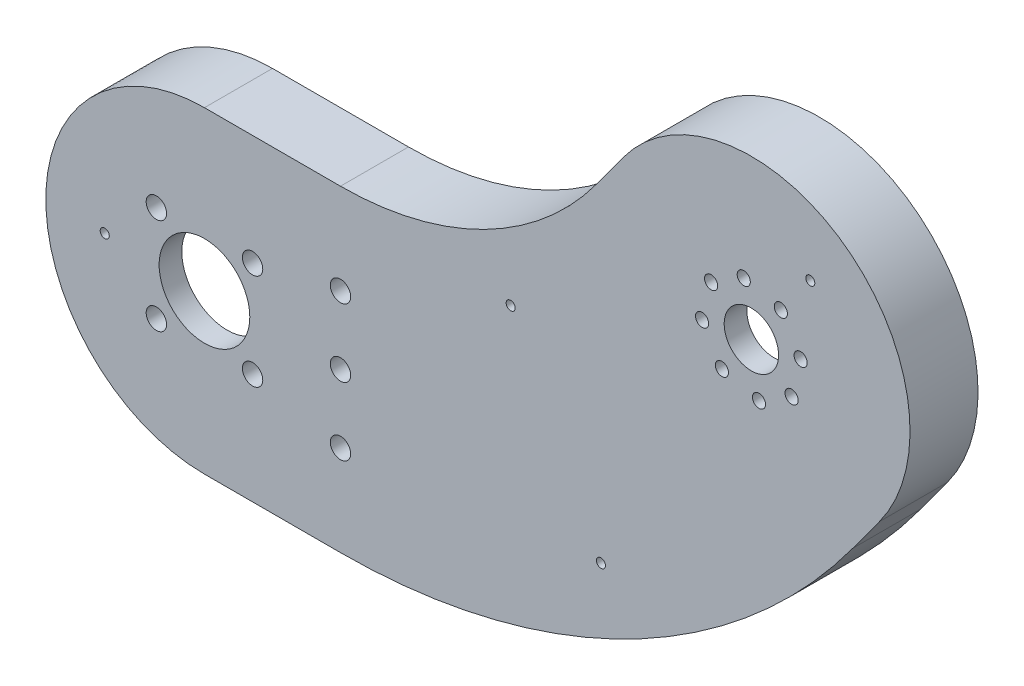
from build123d import *

# Parameters (mm, degrees)
EXTRUDE_1_DEPTH                 = 20
CHAMFER_1_SIZE                  = 10
CUT_EXTRUDE_1_DEPTH             = 15
CUT_EXTRUDE_3_REACH             = 22
SKETCH_4_R                      = 10
SKETCH_4_R_2                    = 2.25
SKETCH_5_R                      = 4
EXTRUDE_2_DEPTH                 = 5
FILLET_1_R                      = 5
CUT_EXTRUDE_4_REACH             = 12
SKETCH_6_R                      = 1
FILLET_2_R                      = 5
CUT_EXTRUDE_5_REACH             = 22
SKETCH_3_R                      = 1.45
SKETCH_3_R_2                    = 6
CUT_EXTRUDE_5_DIRECTION_2_DEPTH = 1.0000001
EXTRUDE_3_DEPTH                 = 13
CUT_EXTRUDE_6_DEPTH             = 5


with BuildPart() as part:
    # 스케치1 → 보스-돌출1 (new body)
    with BuildSketch(Plane.XY):
        with BuildLine():
            Line((0, 35), (30, 35))
            ThreePointArc((30, 35), (61.66442834, 42.571128651), (86.479272091, 63.646743489))
            Line((86.479272091, 63.646743489), (92.386880164, 71.71521093))
            ThreePointArc((92.386880164, 71.71521093), (141.303144465, 79.27821872), (148.866152254, 30.361954419))
            Line((148.866152254, 30.361954419), (142.958544181, 22.293486977))
            ThreePointArc((142.958544181, 22.293486977), (93.32885668, -19.857742698), (30, -35))
            Line((30, -35), (0, -35))
            ThreePointArc((0, -35), (-35, 0), (0, 35))
        make_face()
    extrude(amount=EXTRUDE_1_DEPTH)

    # 모따기1
    chamfer_1_edges = [part.edges().sort_by_distance(p)[0] for p in [
        (15, -35, 0),
        (-35, 0, 0),
        (15, 35, 0),
        (61.66442834, 42.571128651, 0),
        (89.433076127, 67.680977209, 0),
        (141.303144465, 79.27821872, 0),
        (145.912348218, 26.327720698, 0),
        (93.32885668, -19.857742698, 0),
    ]]
    chamfer(chamfer_1_edges, length=CHAMFER_1_SIZE)

    # 스케치2 → 컷-돌출1 (cut)
    with BuildSketch(Plane(origin=(0, 0, 0), x_dir=(-1, 0, 0), z_dir=(0, 0, -1))):
        with BuildLine():
            Line((-30, -25), (0, -25))
            ThreePointArc((0, -25), (25, 0), (0, 25))
            Line((0, 25), (-30, 25))
            ThreePointArc((-30, 25), (-66.187918103, 33.652718458), (-94.547739532, 57.739135415))
            Line((-94.547739532, 57.739135415), (-100.455347605, 65.807602857))
            ThreePointArc((-100.455347605, 65.807602857), (-135.395536392, 71.209751278), (-140.797684813, 36.269562492))
            Line((-140.797684813, 36.269562492), (-134.89007674, 28.20109505))
            ThreePointArc((-134.89007674, 28.20109505), (-88.805366917, -10.939332505), (-30, -25))
        make_face()
    extrude(amount=-CUT_EXTRUDE_1_DEPTH, mode=Mode.SUBTRACT)

    # 스케치4 → 컷-돌출3 (cut, up to next)
    with BuildSketch(Plane.XY.offset(20), mode=Mode.PRIVATE) as cut_extrude_3_sk1:
        Circle(SKETCH_4_R)
    cut_extrude_3_tool1 = extrude(cut_extrude_3_sk1.sketch, amount=-CUT_EXTRUDE_3_REACH, mode=Mode.PRIVATE) & part.part
    add(cut_extrude_3_tool1.solids().sort_by_distance((0, 0, 20))[0], mode=Mode.SUBTRACT)
    # 스케치4 → 컷-돌출3 (cut, up to next)
    with BuildSketch(Plane.XY.offset(20), mode=Mode.PRIVATE) as cut_extrude_3_sk2:
        with Locations((10.606601718, 10.606601718)):
            Circle(SKETCH_4_R_2)
    cut_extrude_3_tool2 = extrude(cut_extrude_3_sk2.sketch, amount=-CUT_EXTRUDE_3_REACH, mode=Mode.PRIVATE) & part.part
    add(cut_extrude_3_tool2.solids().sort_by_distance((10.606602, 10.606602, 20))[0], mode=Mode.SUBTRACT)
    # 스케치4 → 컷-돌출3 (cut, up to next)
    with BuildSketch(Plane.XY.offset(20), mode=Mode.PRIVATE) as cut_extrude_3_sk3:
        with Locations((-10.606601718, -10.606601718)):
            Circle(SKETCH_4_R_2)
    cut_extrude_3_tool3 = extrude(cut_extrude_3_sk3.sketch, amount=-CUT_EXTRUDE_3_REACH, mode=Mode.PRIVATE) & part.part
    add(cut_extrude_3_tool3.solids().sort_by_distance((-10.606602, -10.606602, 20))[0], mode=Mode.SUBTRACT)
    # 스케치4 → 컷-돌출3 (cut, up to next)
    with BuildSketch(Plane.XY.offset(20), mode=Mode.PRIVATE) as cut_extrude_3_sk4:
        with Locations((10.606601718, -10.606601718)):
            Circle(SKETCH_4_R_2)
    cut_extrude_3_tool4 = extrude(cut_extrude_3_sk4.sketch, amount=-CUT_EXTRUDE_3_REACH, mode=Mode.PRIVATE) & part.part
    add(cut_extrude_3_tool4.solids().sort_by_distance((10.606602, -10.606602, 20))[0], mode=Mode.SUBTRACT)
    # 스케치4 → 컷-돌출3 (cut, up to next)
    with BuildSketch(Plane.XY.offset(20), mode=Mode.PRIVATE) as cut_extrude_3_sk5:
        with Locations((-10.606601718, 10.606601718)):
            Circle(SKETCH_4_R_2)
    cut_extrude_3_tool5 = extrude(cut_extrude_3_sk5.sketch, amount=-CUT_EXTRUDE_3_REACH, mode=Mode.PRIVATE) & part.part
    add(cut_extrude_3_tool5.solids().sort_by_distance((-10.606602, 10.606602, 20))[0], mode=Mode.SUBTRACT)
    # 스케치4 → 컷-돌출3 (cut, up to next)
    with BuildSketch(Plane.XY.offset(20), mode=Mode.PRIVATE) as cut_extrude_3_sk6:
        with Locations((30, 0)):
            Circle(SKETCH_4_R_2)
    cut_extrude_3_tool6 = extrude(cut_extrude_3_sk6.sketch, amount=-CUT_EXTRUDE_3_REACH, mode=Mode.PRIVATE) & part.part
    add(cut_extrude_3_tool6.solids().sort_by_distance((30, 0, 20))[0], mode=Mode.SUBTRACT)
    # 스케치4 → 컷-돌출3 (cut, up to next)
    with BuildSketch(Plane.XY.offset(20), mode=Mode.PRIVATE) as cut_extrude_3_sk7:
        with Locations((30, 15)):
            Circle(SKETCH_4_R_2)
    cut_extrude_3_tool7 = extrude(cut_extrude_3_sk7.sketch, amount=-CUT_EXTRUDE_3_REACH, mode=Mode.PRIVATE) & part.part
    add(cut_extrude_3_tool7.solids().sort_by_distance((30, 15, 20))[0], mode=Mode.SUBTRACT)
    # 스케치4 → 컷-돌출3 (cut, up to next)
    with BuildSketch(Plane.XY.offset(20), mode=Mode.PRIVATE) as cut_extrude_3_sk8:
        with Locations((30, -15)):
            Circle(SKETCH_4_R_2)
    cut_extrude_3_tool8 = extrude(cut_extrude_3_sk8.sketch, amount=-CUT_EXTRUDE_3_REACH, mode=Mode.PRIVATE) & part.part
    add(cut_extrude_3_tool8.solids().sort_by_distance((30, -15, 20))[0], mode=Mode.SUBTRACT)

    # 스케치5 → 보스-돌출2 (add)
    with BuildSketch(Plane(origin=(0, 0, 15), x_dir=(-1, 0, 0), z_dir=(0, 0, -1))):
        with Locations((-87.448319988, -8.263809447)):
            Circle(SKETCH_5_R)
        with Locations((22, 0)):
            Circle(SKETCH_5_R)
        with Locations((-67.544965032, 30.977195401)):
            Circle(SKETCH_5_R)
        with Locations((-133.62325397, 68.789211046)):
            Circle(SKETCH_5_R)
    extrude(amount=EXTRUDE_2_DEPTH)

    # 필렛1
    fillet_1_edges = [part.edges().sort_by_distance(p)[0] for p in [
        (86.405731085, -12.125545893, 12.5),
        (91.180070129, -9.703962525, 12.5),
        (-24.840909091, 2.81588983, 12.5),
        (-24.840909091, -2.81588983, 12.5),
        (63.852594529, 32.515506185, 12.5),
        (68.485091763, 34.86514624, 12.5),
        (137.573543259, 69.417871947, 12.5),
        (133.029560176, 72.744906646, 12.5),
    ]]
    fillet(fillet_1_edges, radius=FILLET_1_R)

    # 스케치6 → 컷-돌출4 (cut, up to next)
    with BuildSketch(Plane(origin=(0, 0, 10), x_dir=(-1, 0, 0), z_dir=(0, 0, -1)), mode=Mode.PRIVATE) as cut_extrude_4_sk1:
        with Locations((-87.448319988, -8.263809447)):
            Circle(SKETCH_6_R)
    cut_extrude_4_tool1 = extrude(cut_extrude_4_sk1.sketch, amount=-CUT_EXTRUDE_4_REACH, mode=Mode.PRIVATE) & part.part
    add(cut_extrude_4_tool1.solids().sort_by_distance((87.44832, -8.263809, 10))[0], mode=Mode.SUBTRACT)
    # 스케치6 → 컷-돌출4 (cut, up to next)
    with BuildSketch(Plane(origin=(0, 0, 10), x_dir=(-1, 0, 0), z_dir=(0, 0, -1)), mode=Mode.PRIVATE) as cut_extrude_4_sk2:
        with Locations((22, 0)):
            Circle(SKETCH_6_R)
    cut_extrude_4_tool2 = extrude(cut_extrude_4_sk2.sketch, amount=-CUT_EXTRUDE_4_REACH, mode=Mode.PRIVATE) & part.part
    add(cut_extrude_4_tool2.solids().sort_by_distance((-22, 0, 10))[0], mode=Mode.SUBTRACT)
    # 스케치6 → 컷-돌출4 (cut, up to next)
    with BuildSketch(Plane(origin=(0, 0, 10), x_dir=(-1, 0, 0), z_dir=(0, 0, -1)), mode=Mode.PRIVATE) as cut_extrude_4_sk3:
        with Locations((-67.544965032, 30.977195401)):
            Circle(SKETCH_6_R)
    cut_extrude_4_tool3 = extrude(cut_extrude_4_sk3.sketch, amount=-CUT_EXTRUDE_4_REACH, mode=Mode.PRIVATE) & part.part
    add(cut_extrude_4_tool3.solids().sort_by_distance((67.544965, 30.977195, 10))[0], mode=Mode.SUBTRACT)
    # 스케치6 → 컷-돌출4 (cut, up to next)
    with BuildSketch(Plane(origin=(0, 0, 10), x_dir=(-1, 0, 0), z_dir=(0, 0, -1)), mode=Mode.PRIVATE) as cut_extrude_4_sk4:
        with Locations((-133.62325397, 68.789211046)):
            Circle(SKETCH_6_R)
    cut_extrude_4_tool4 = extrude(cut_extrude_4_sk4.sketch, amount=-CUT_EXTRUDE_4_REACH, mode=Mode.PRIVATE) & part.part
    add(cut_extrude_4_tool4.solids().sort_by_distance((133.623254, 68.789211, 10))[0], mode=Mode.SUBTRACT)

    # 필렛2
    fillet_2_edges = [part.edges().sort_by_distance(p)[0] for p in [
        (-35, 0, 10),
        (15, -35, 10),
        (15, 35, 10),
        (93.32885668, -19.857742698, 10),
        (61.66442834, 42.571128651, 10),
        (145.912348218, 26.327720698, 10),
        (89.433076127, 67.680977209, 10),
        (141.303144465, 79.27821872, 10),
    ]]
    fillet(fillet_2_edges, radius=FILLET_2_R)

    # 스케치3 → 컷-돌출5 (cut, up to next)
    with BuildSketch(Plane.XY.offset(20), mode=Mode.PRIVATE) as cut_extrude_5_sk1:
        with Locations((127.12488509, 59.91389686)):
            Circle(SKETCH_3_R)
    cut_extrude_5_tool1 = extrude(cut_extrude_5_sk1.sketch, amount=-CUT_EXTRUDE_5_REACH, mode=Mode.PRIVATE) & part.part
    add(cut_extrude_5_tool1.solids().sort_by_distance((127.124885, 59.913897, 20))[0], mode=Mode.SUBTRACT)
    # 스케치3 → 컷-돌출5 (cut, up to next)
    with BuildSketch(Plane.XY.offset(20), mode=Mode.PRIVATE) as cut_extrude_5_sk2:
        with Locations((129.501830395, 44.540213794)):
            Circle(SKETCH_3_R)
    cut_extrude_5_tool2 = extrude(cut_extrude_5_sk2.sketch, amount=-CUT_EXTRUDE_5_REACH, mode=Mode.PRIVATE) & part.part
    add(cut_extrude_5_tool2.solids().sort_by_distance((129.50183, 44.540214, 20))[0], mode=Mode.SUBTRACT)
    # 스케치3 → 컷-돌출5 (cut, up to next)
    with BuildSketch(Plane.XY.offset(20), mode=Mode.PRIVATE) as cut_extrude_5_sk3:
        with Locations((114.128147329, 42.163268489)):
            Circle(SKETCH_3_R)
    cut_extrude_5_tool3 = extrude(cut_extrude_5_sk3.sketch, amount=-CUT_EXTRUDE_5_REACH, mode=Mode.PRIVATE) & part.part
    add(cut_extrude_5_tool3.solids().sort_by_distance((114.128147, 42.163268, 20))[0], mode=Mode.SUBTRACT)
    # 스케치3 → 컷-돌출5 (cut, up to next)
    with BuildSketch(Plane.XY.offset(20), mode=Mode.PRIVATE) as cut_extrude_5_sk4:
        with Locations((111.751202023, 57.536951555)):
            Circle(SKETCH_3_R)
    cut_extrude_5_tool4 = extrude(cut_extrude_5_sk4.sketch, amount=-CUT_EXTRUDE_5_REACH, mode=Mode.PRIVATE) & part.part
    add(cut_extrude_5_tool4.solids().sort_by_distance((111.751202, 57.536952, 20))[0], mode=Mode.SUBTRACT)
    # 스케치3 → 컷-돌출5 (cut, up to next)
    with BuildSketch(Plane.XY.offset(20), mode=Mode.PRIVATE) as cut_extrude_5_sk5:
        with Locations((120.626516209, 51.038582674)):
            Circle(SKETCH_3_R_2)
    cut_extrude_5_tool5 = extrude(cut_extrude_5_sk5.sketch, amount=-CUT_EXTRUDE_5_REACH, mode=Mode.PRIVATE) & part.part
    add(cut_extrude_5_tool5.solids().sort_by_distance((120.626516, 51.038583, 20))[0], mode=Mode.SUBTRACT)
    # 스케치3 → 컷-돌출5 (cut, up to next)
    with BuildSketch(Plane.XY.offset(20), mode=Mode.PRIVATE) as cut_extrude_5_sk6:
        with Locations((118.945762065, 61.909418222)):
            Circle(SKETCH_3_R)
    cut_extrude_5_tool6 = extrude(cut_extrude_5_sk6.sketch, amount=-CUT_EXTRUDE_5_REACH, mode=Mode.PRIVATE) & part.part
    add(cut_extrude_5_tool6.solids().sort_by_distance((118.945762, 61.909418, 20))[0], mode=Mode.SUBTRACT)
    # 스케치3 → 컷-돌출5 (cut, up to next)
    with BuildSketch(Plane.XY.offset(20), mode=Mode.PRIVATE) as cut_extrude_5_sk7:
        with Locations((131.497351757, 52.719336818)):
            Circle(SKETCH_3_R)
    cut_extrude_5_tool7 = extrude(cut_extrude_5_sk7.sketch, amount=-CUT_EXTRUDE_5_REACH, mode=Mode.PRIVATE) & part.part
    add(cut_extrude_5_tool7.solids().sort_by_distance((131.497352, 52.719337, 20))[0], mode=Mode.SUBTRACT)
    # 스케치3 → 컷-돌출5 (cut, up to next)
    with BuildSketch(Plane.XY.offset(20), mode=Mode.PRIVATE) as cut_extrude_5_sk8:
        with Locations((122.307270353, 40.167747126)):
            Circle(SKETCH_3_R)
    cut_extrude_5_tool8 = extrude(cut_extrude_5_sk8.sketch, amount=-CUT_EXTRUDE_5_REACH, mode=Mode.PRIVATE) & part.part
    add(cut_extrude_5_tool8.solids().sort_by_distance((122.30727, 40.167747, 20))[0], mode=Mode.SUBTRACT)
    # 스케치3 → 컷-돌출5 (cut, up to next)
    with BuildSketch(Plane.XY.offset(20), mode=Mode.PRIVATE) as cut_extrude_5_sk9:
        with Locations((109.755680661, 49.35782853)):
            Circle(SKETCH_3_R)
    cut_extrude_5_tool9 = extrude(cut_extrude_5_sk9.sketch, amount=-CUT_EXTRUDE_5_REACH, mode=Mode.PRIVATE) & part.part
    add(cut_extrude_5_tool9.solids().sort_by_distance((109.755681, 49.357829, 20))[0], mode=Mode.SUBTRACT)

    # 스케치3 → 컷-돌출5 direction 2 (cut)
    with BuildSketch(Plane.XY.offset(20)):
        with Locations((127.12488509, 59.91389686)):
            Circle(SKETCH_3_R)
        with Locations((129.501830395, 44.540213794)):
            Circle(SKETCH_3_R)
        with Locations((114.128147329, 42.163268489)):
            Circle(SKETCH_3_R)
        with Locations((111.751202023, 57.536951555)):
            Circle(SKETCH_3_R)
        with Locations((120.626516209, 51.038582674)):
            Circle(SKETCH_3_R_2)
        with Locations((118.945762065, 61.909418222)):
            Circle(SKETCH_3_R)
        with Locations((131.497351757, 52.719336818)):
            Circle(SKETCH_3_R)
        with Locations((122.307270353, 40.167747126)):
            Circle(SKETCH_3_R)
        with Locations((109.755680661, 49.35782853)):
            Circle(SKETCH_3_R)
    extrude(amount=CUT_EXTRUDE_5_DIRECTION_2_DEPTH, mode=Mode.SUBTRACT)

    # 스케치7 → 보스-돌출3 (add)
    with BuildSketch(Plane.XY):
        with BuildLine():
            Line((142.958544181, 22.293486977), (148.866152254, 30.361954419))
            ThreePointArc((148.866152254, 30.361954419), (141.303144465, 79.27821872), (92.386880164, 71.71521093))
            Line((92.386880164, 71.71521093), (86.479272091, 63.646743489))
            ThreePointArc((86.479272091, 63.646743489), (61.66442834, 42.571128651), (30, 35))
            Line((30, 35), (0, 35))
            ThreePointArc((0, 35), (-35, 0), (0, -35))
            Line((0, -35), (30, -35))
            ThreePointArc((30, -35), (93.32885668, -19.857742698), (142.958544181, 22.293486977))
        make_face()
        with BuildLine():
            Line((134.89007674, 28.20109505), (140.797684813, 36.269562492))
            ThreePointArc((140.797684813, 36.269562492), (135.395536392, 71.209751278), (100.455347605, 65.807602857))
            Line((100.455347605, 65.807602857), (94.547739532, 57.739135415))
            ThreePointArc((94.547739532, 57.739135415), (66.187918103, 33.652718458), (30, 25))
            Line((30, 25), (0, 25))
            ThreePointArc((0, 25), (-25, 0), (0, -25))
            Line((0, -25), (30, -25))
            ThreePointArc((30, -25), (88.805366917, -10.939332505), (134.89007674, 28.20109505))
        make_face(mode=Mode.SUBTRACT)
    extrude(amount=EXTRUDE_3_DEPTH)

    # 스케치8 → 컷-돌출6 (cut)
    with BuildSketch(Plane(origin=(0, 0, 0), x_dir=(-1, 0, 0), z_dir=(0, 0, -1))):
        with BuildLine():
            Line((-148.866152254, 30.361954419), (-142.958544181, 22.293486977))
            ThreePointArc((-142.958544181, 22.293486977), (-93.32885668, -19.857742698), (-30, -35))
            Line((-30, -35), (0, -35))
            ThreePointArc((0, -35), (35, 0), (0, 35))
            Line((0, 35), (-30, 35))
            ThreePointArc((-30, 35), (-61.66442834, 42.571128651), (-86.479272091, 63.646743489))
            Line((-86.479272091, 63.646743489), (-92.386880164, 71.71521093))
            ThreePointArc((-92.386880164, 71.71521093), (-141.303144465, 79.27821872), (-148.866152254, 30.361954419))
        make_face()
        with BuildLine():
            Line((-140.797684813, 36.269562492), (-134.89007674, 28.20109505))
            ThreePointArc((-134.89007674, 28.20109505), (-88.805366917, -10.939332505), (-30, -25))
            Line((-30, -25), (0, -25))
            ThreePointArc((0, -25), (25, 0), (0, 25))
            Line((0, 25), (-30, 25))
            ThreePointArc((-30, 25), (-66.187918103, 33.652718458), (-94.547739532, 57.739135415))
            Line((-94.547739532, 57.739135415), (-100.455347605, 65.807602857))
            ThreePointArc((-100.455347605, 65.807602857), (-135.395536392, 71.209751278), (-140.797684813, 36.269562492))
        make_face(mode=Mode.SUBTRACT)
    extrude(amount=-CUT_EXTRUDE_6_DEPTH, mode=Mode.SUBTRACT)


solid = part.part
